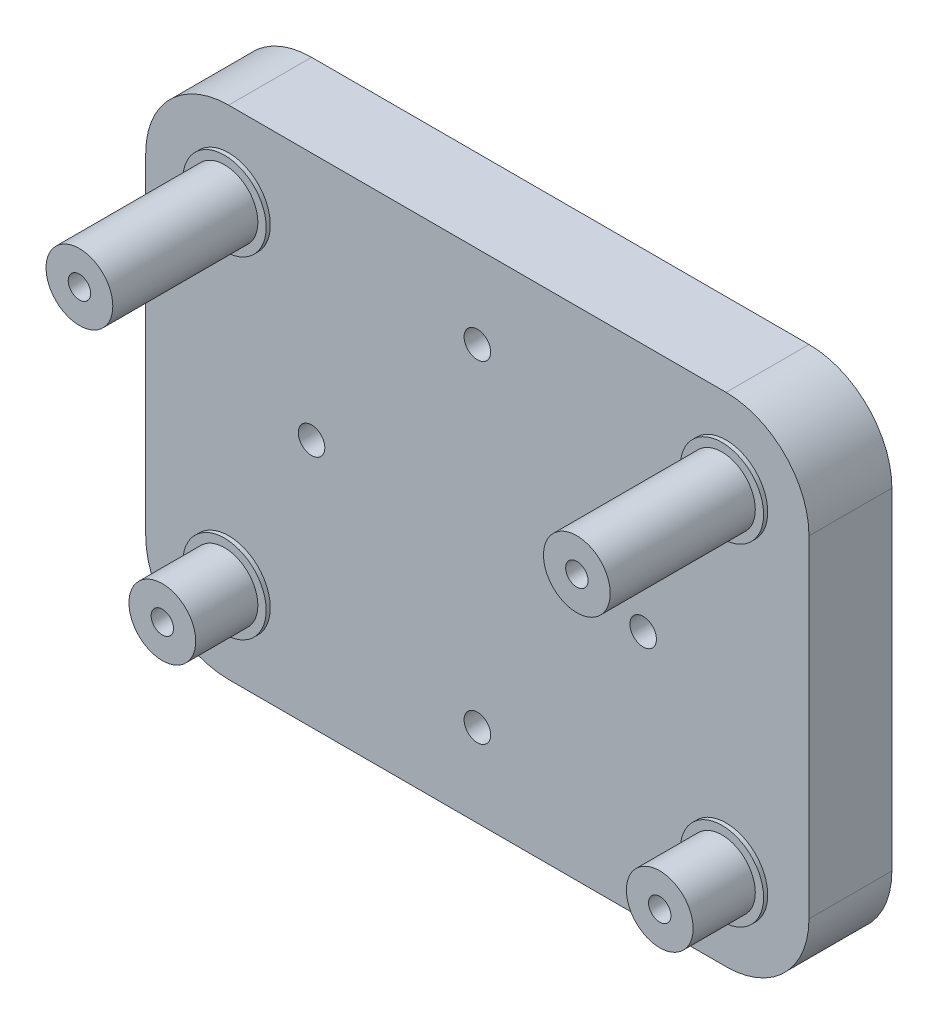
from build123d import *

# Parameters (mm, degrees)
SKETCH1_W               = 80
SKETCH1_H               = 60
BOSS_EXTRUDE1_DEPTH     = 10
SKETCH1_3_R             = 4.025
SKETCH1_3_R_2           = 1.35
BOSS_EXTRUDE2_DEPTH     = 8
SKETCH1_5_R             = 4.025
SKETCH1_5_R_2           = 1.35
BOSS_EXTRUDE4_DEPTH     = 18
SKETCH1_4_R             = 5.025
SKETCH1_4_R_2           = 4.025
BOSS_EXTRUDE3_DEPTH     = 0.5
CUT_EXTRUDE1_DEPTH      = 54.141321022
CUT_EXTRUDE1_DEPTH_BACK = 54.141321022
SKETCH1_6_R             = 1.6
FILLET1_R               = 10


with BuildPart() as part:
    # Sketch1 → Boss-Extrude1 (new body)
    with BuildSketch(Plane.XY):
        Rectangle(SKETCH1_W, SKETCH1_H)
    extrude(amount=-BOSS_EXTRUDE1_DEPTH)

    # Sketch1_3 → Boss-Extrude2 (add)
    # profile 1 of 2: a face of its own
    with BuildSketch(Plane.XY):
        with Locations((-30, -20)):
            Circle(SKETCH1_3_R)
        with Locations((-30, -20)):
            Circle(SKETCH1_3_R_2, mode=Mode.SUBTRACT)
    # profile 2 of 2: a face of its own
    with BuildSketch(Plane.XY):
        with Locations((30, -20)):
            Circle(SKETCH1_3_R)
        with Locations((30, -20)):
            Circle(SKETCH1_3_R_2, mode=Mode.SUBTRACT)
    extrude(amount=BOSS_EXTRUDE2_DEPTH)

    # Sketch1_5 → Boss-Extrude4 (add)
    # profile 1 of 2: a face of its own
    with BuildSketch(Plane.XY):
        with Locations((-30, 20)):
            Circle(SKETCH1_5_R)
        with Locations((-30, 20)):
            Circle(SKETCH1_5_R_2, mode=Mode.SUBTRACT)
    # profile 2 of 2: a face of its own
    with BuildSketch(Plane.XY):
        with Locations((30, 20)):
            Circle(SKETCH1_5_R)
        with Locations((30, 20)):
            Circle(SKETCH1_5_R_2, mode=Mode.SUBTRACT)
    extrude(amount=BOSS_EXTRUDE4_DEPTH)

    # Sketch1_4 → Boss-Extrude3 (add)
    # profile 1 of 4: a face of its own
    with BuildSketch(Plane.XY):
        with Locations((-30, 20)):
            Circle(SKETCH1_4_R)
        with Locations((-30, 20)):
            Circle(SKETCH1_4_R_2, mode=Mode.SUBTRACT)
    # profile 2 of 4: a face of its own
    with BuildSketch(Plane.XY):
        with Locations((30, 20)):
            Circle(SKETCH1_4_R)
        with Locations((30, 20)):
            Circle(SKETCH1_4_R_2, mode=Mode.SUBTRACT)
    # profile 3 of 4: a face of its own
    with BuildSketch(Plane.XY):
        with Locations((30, -20)):
            Circle(SKETCH1_4_R)
        with Locations((30, -20)):
            Circle(SKETCH1_4_R_2, mode=Mode.SUBTRACT)
    # profile 4 of 4: a face of its own
    with BuildSketch(Plane.XY):
        with Locations((-30, -20)):
            Circle(SKETCH1_4_R)
        with Locations((-30, -20)):
            Circle(SKETCH1_4_R_2, mode=Mode.SUBTRACT)
    extrude(amount=BOSS_EXTRUDE3_DEPTH)

    # Sketch1_6 → Cut-Extrude1 (cut, two sides: drawn at the far end of the back side and taken through both)
    with BuildSketch(Plane.XY.offset(-CUT_EXTRUDE1_DEPTH_BACK)):
        with Locations((-20, 0)):
            Circle(SKETCH1_6_R)
        with Locations((0, 20)):
            Circle(SKETCH1_6_R)
        with Locations((20, 0)):
            Circle(SKETCH1_6_R)
        with Locations((0, -20)):
            Circle(SKETCH1_6_R)
    extrude(amount=CUT_EXTRUDE1_DEPTH + CUT_EXTRUDE1_DEPTH_BACK, mode=Mode.SUBTRACT)

    # Fillet1
    fillet1_edges = [part.edges().sort_by_distance(p)[0] for p in [
        (40, 30, -5),
        (40, -30, -5),
        (-40, -30, -5),
        (-40, 30, -5),
    ]]
    fillet(fillet1_edges, radius=FILLET1_R)


solid = part.part
